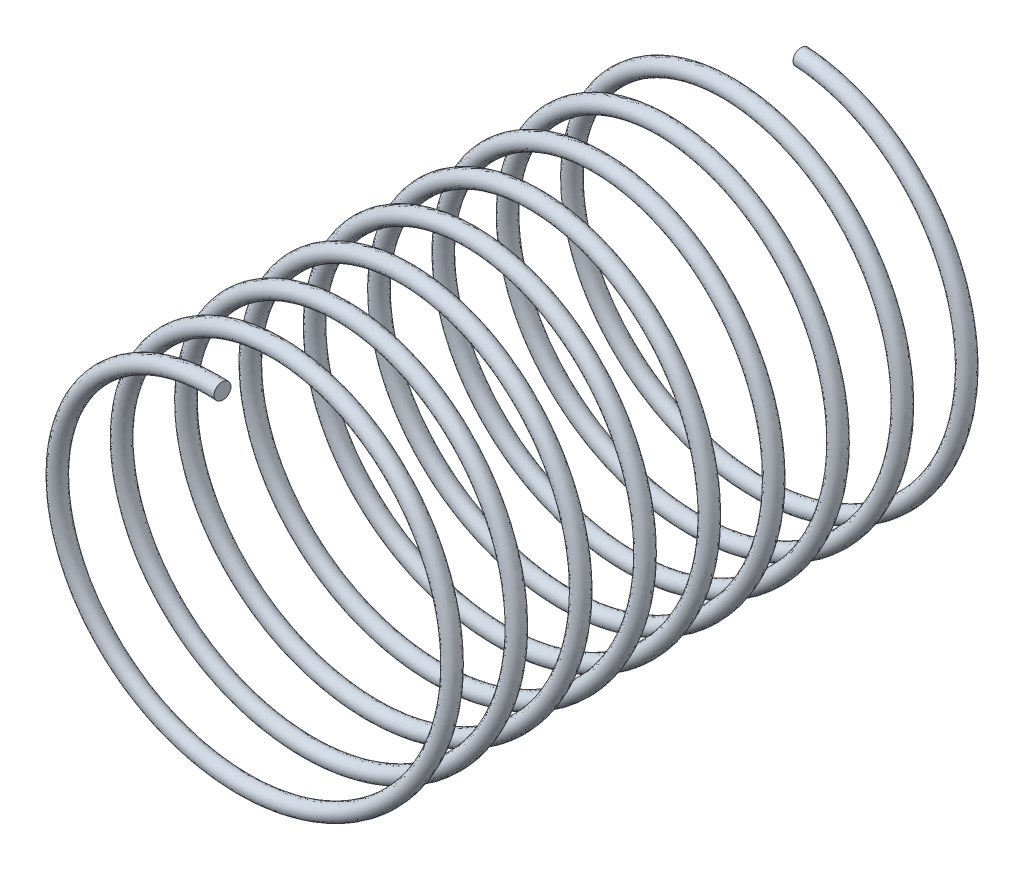
from build123d import *

# Parameters (mm, degrees)
SWEEP1_PITCH       = 10.16
SWEEP1_HEIGHT      = 91.44
SWEEP1_RADIUS      = 28.575
SWEEP1_START_ANGLE = 90
SWEEP1_PROFILE_R   = 1.27


with BuildPart() as part:
    # Sweep1: sweep along a helix
    with BuildLine() as sweep1_path:
        add(Helix(SWEEP1_PITCH, SWEEP1_HEIGHT, SWEEP1_RADIUS, center=(0, 0, 0), direction=(0, 0, 1), lefthand=True, mode=Mode.PRIVATE).rotate(Axis((0, 0, 0), (0, 0, 1)), SWEEP1_START_ANGLE))
    # Sweep1 profile (on start of the path) → Sweep1 (sweep)
    with BuildSketch(Plane(origin=(0, 28.575, 0), x_dir=(-0.056498036, 0, 0.99840271), z_dir=(0.99840271, 0, 0.056498036))):
        Circle(SWEEP1_PROFILE_R)
    sweep(path=sweep1_path.line, is_frenet=True)


solid = part.part
